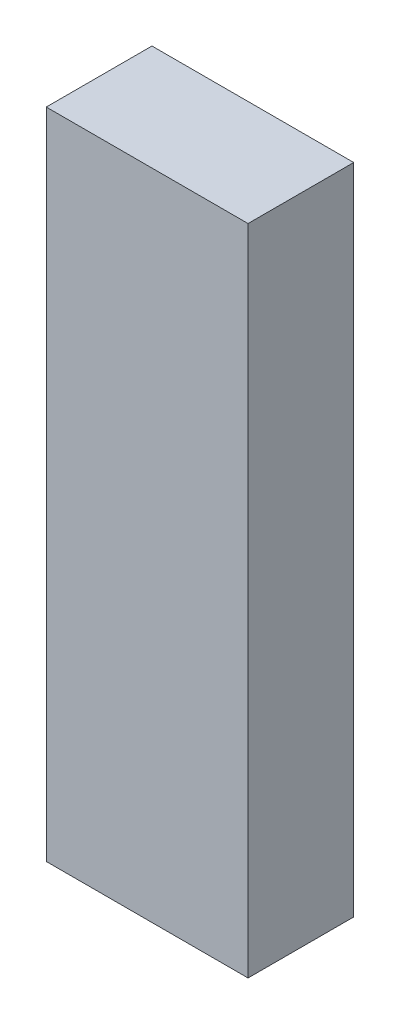
from build123d import *

# Parameters (mm, degrees)
SKETCH1_W           = 42
SKETCH1_H           = 22
BOSS_EXTRUDE1_DEPTH = 136


with BuildPart() as part:
    # Sketch1 → Boss-Extrude1 (new body)
    with BuildSketch(Plane(origin=(0, 0, 0), x_dir=(1, 0, 0), z_dir=(0, 1, 0))):
        Rectangle(SKETCH1_W, SKETCH1_H)
    extrude(amount=BOSS_EXTRUDE1_DEPTH)


solid = part.part
